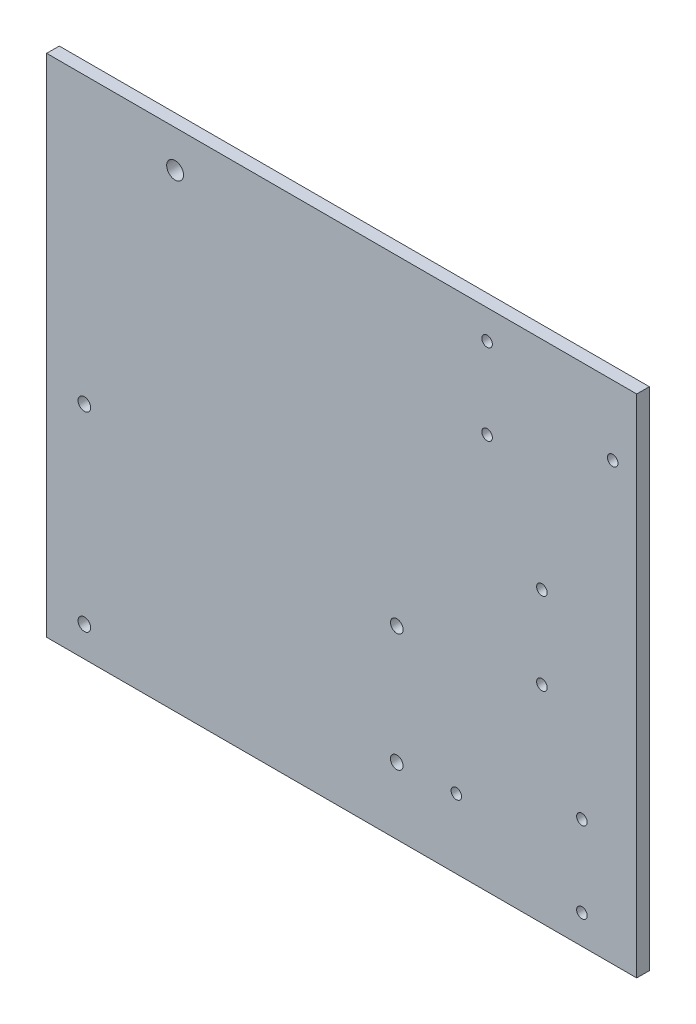
from build123d import *

# Parameters (mm, degrees)
SKETCH1_W           = 140
SKETCH1_H           = 120
SKETCH1_R           = 2
SKETCH1_R_2         = 1.5
SKETCH1_R_3         = 1.25
BOSS_EXTRUDE1_DEPTH = 3


with BuildPart() as part:
    # Sketch1 → Boss-Extrude1 (new body)
    with BuildSketch(Plane.XY):
        with Locations((-70, 60)):
            Rectangle(SKETCH1_W, SKETCH1_H)
        with Locations((-109.522973194, 111.205068666)):
            Circle(SKETCH1_R, mode=Mode.SUBTRACT)
        with Locations((-131.05, 7.17)):
            Circle(SKETCH1_R_2, mode=Mode.SUBTRACT)
        with Locations((-131.05, 52.41)):
            Circle(SKETCH1_R_2, mode=Mode.SUBTRACT)
        with Locations((-56.93, 15.86)):
            Circle(SKETCH1_R_2, mode=Mode.SUBTRACT)
        with Locations((-56.93, 43.86)):
            Circle(SKETCH1_R_2, mode=Mode.SUBTRACT)
        with Locations((-13, 6.91)):
            Circle(SKETCH1_R_3, mode=Mode.SUBTRACT)
        with Locations((-13, 26.11)):
            Circle(SKETCH1_R_3, mode=Mode.SUBTRACT)
        with Locations((-42.8, 16.5)):
            Circle(SKETCH1_R_3, mode=Mode.SUBTRACT)
        with Locations((-35.5, 93.89)):
            Circle(SKETCH1_R_3, mode=Mode.SUBTRACT)
        with Locations((-35.5, 113.09)):
            Circle(SKETCH1_R_3, mode=Mode.SUBTRACT)
        with Locations((-5.7, 103.5)):
            Circle(SKETCH1_R_3, mode=Mode.SUBTRACT)
        with Locations((-22.5, 68.527626294)):
            Circle(SKETCH1_R_3, mode=Mode.SUBTRACT)
        with Locations((-22.5, 49.027626294)):
            Circle(SKETCH1_R_3, mode=Mode.SUBTRACT)
    extrude(amount=BOSS_EXTRUDE1_DEPTH)


solid = part.part
